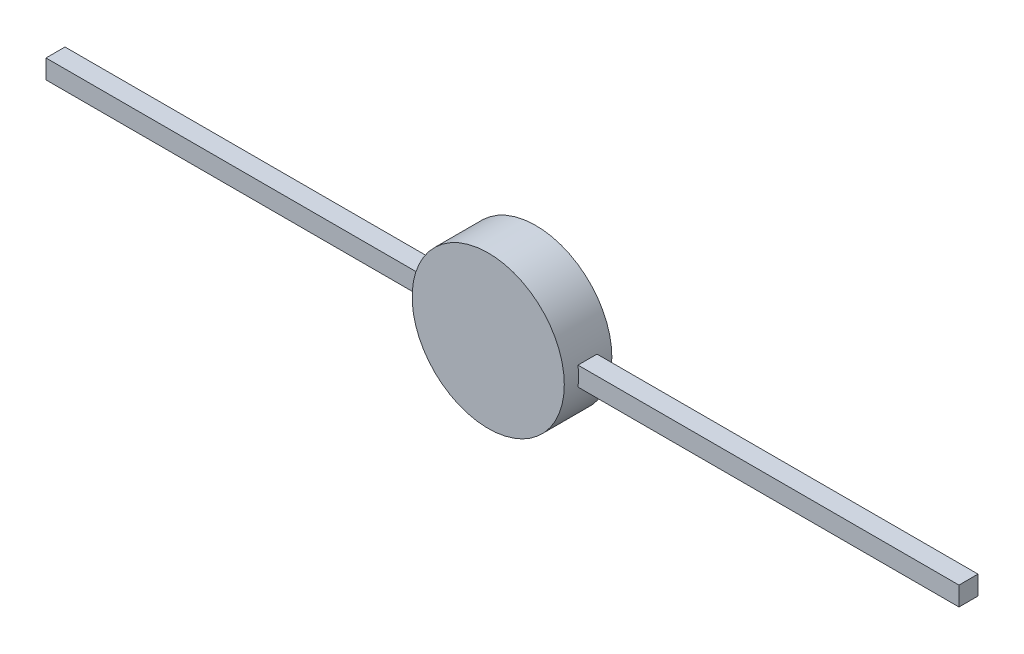
from build123d import *

# Parameters (mm, degrees)
SKETCH1_R           = 8
BOSS_EXTRUDE1_DEPTH = 5
SKETCH2_W           = 2
SKETCH2_H           = 2
BOSS_EXTRUDE2_DEPTH = 48


with BuildPart() as part:
    # Sketch1 → Boss-Extrude1 (new body)
    with BuildSketch(Plane.XY):
        Circle(SKETCH1_R)
    extrude(amount=BOSS_EXTRUDE1_DEPTH)

    # Sketch2 → Boss-Extrude2 (add)
    with BuildSketch(Plane.ZY.offset(48)):
        with Locations((2.5, 0)):
            Rectangle(SKETCH2_W, SKETCH2_H)
    boss_extrude2 = extrude(amount=-BOSS_EXTRUDE2_DEPTH)

    # Mirror1: Boss-Extrude2 across plane
    add(boss_extrude2.mirror(Plane(origin=(0, 0, 0), x_dir=(0, 0, 1), z_dir=(1, 0, 0))))


solid = part.part
